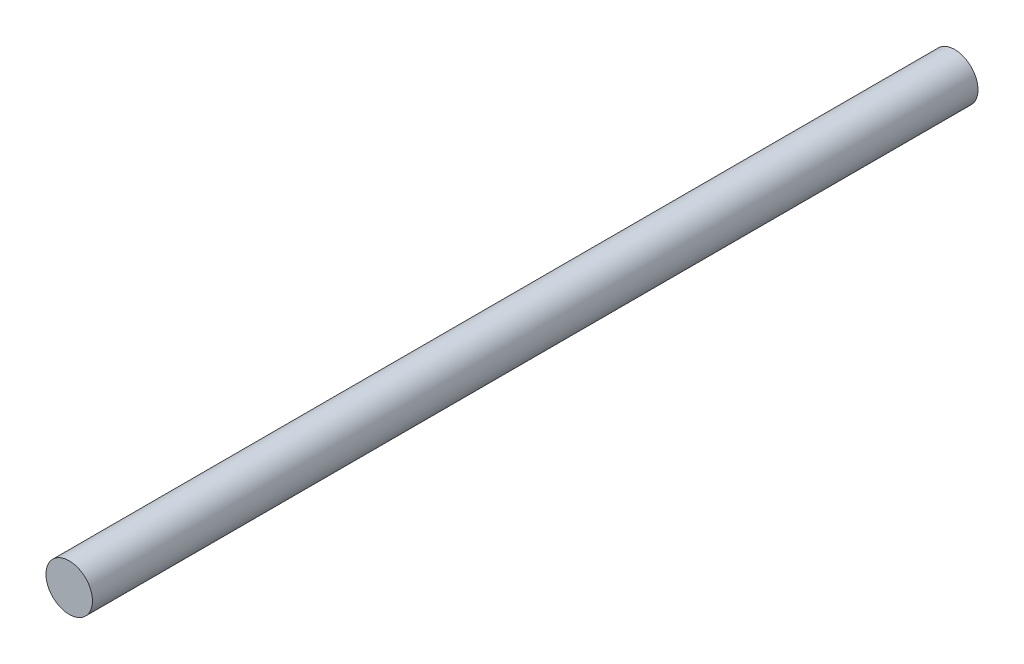
from build123d import *

# Parameters (mm, degrees)
SKETCH_1_R      = 2.1
EXTRUDE_1_DEPTH = 80


with BuildPart() as part:
    # 草图1 → 凸台-拉伸1 (new body)
    with BuildSketch(Plane.XY):
        Circle(SKETCH_1_R)
    extrude(amount=EXTRUDE_1_DEPTH)


solid = part.part
